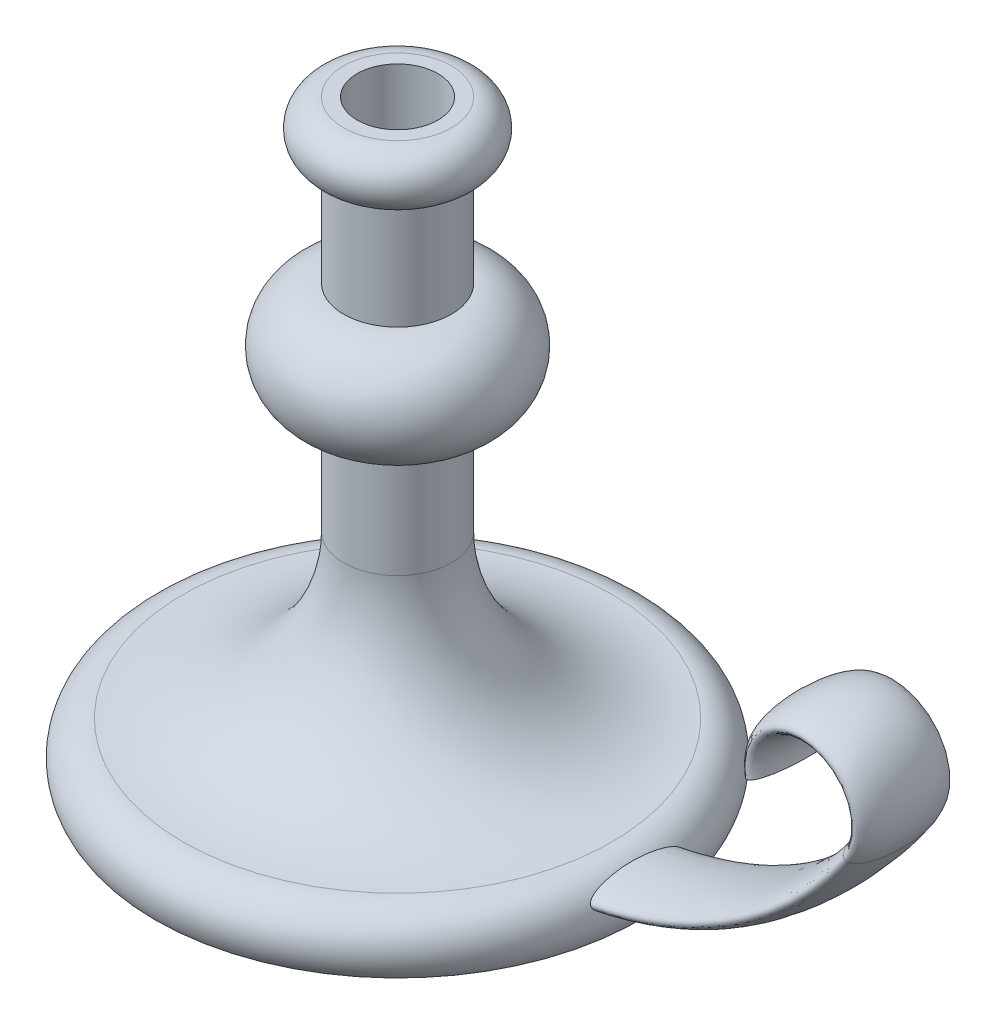
from build123d import *

# Parameters (mm, degrees)
SKETCH7_RX         = 17.5
SKETCH7_RY         = 5
SKETCH8_R          = 15
CUT_EXTRUDE1_DEPTH = 25


with BuildPart() as part:
    # Sketch5 → Revolve1 (revolve)
    with BuildSketch(Plane.XY):
        with BuildLine():
            Line((0, 0), (0, 220))
            Line((0, 220), (20, 220))
            ThreePointArc((20, 220), (30, 210), (20, 200))
            Line((20, 200), (20, 160))
            ThreePointArc((20, 160), (40, 140), (20, 120))
            Line((20, 120), (20, 80))
            ThreePointArc((20, 80), (37.468057592, 37.679391841), (79.701129166, 20.000744369))
            ThreePointArc((79.701129166, 20.000744369), (90.915304764, 13.123254744), (90, 0))
            Line((90, 0), (0, 0))
        make_face()
    revolve(axis=Axis((0, 0, 0), (0, 1, 0)))

    # Sweep2: sweep along a path in Sketch6
    with BuildLine(Plane.XY) as sweep2_path:
        Line((0, 10), (60, 10))
        ThreePointArc((60, 10), (129.821200219, 27.240819526), (183.592070943, 75))
        ThreePointArc((183.592070943, 75), (171.272665171, 105.896008298), (147.448696612, 82.685027935))
    # Sketch7 → Sweep2 (sweep)
    with BuildSketch(Plane(origin=(0, 0, 0), x_dir=(0, 0, -1), z_dir=(1, 0, 0))):
        with Locations(Location((0, 10), (0, 0, 180))):
            Ellipse(SKETCH7_RX, SKETCH7_RY)
    sweep(path=sweep2_path.line)

    # Sketch8 → Cut-Extrude1 (cut)
    with BuildSketch(Plane(origin=(0, 220, 0), x_dir=(1, 0, 0), z_dir=(0, 1, 0))):
        Circle(SKETCH8_R)
    extrude(amount=-CUT_EXTRUDE1_DEPTH, mode=Mode.SUBTRACT)


solid = part.part
